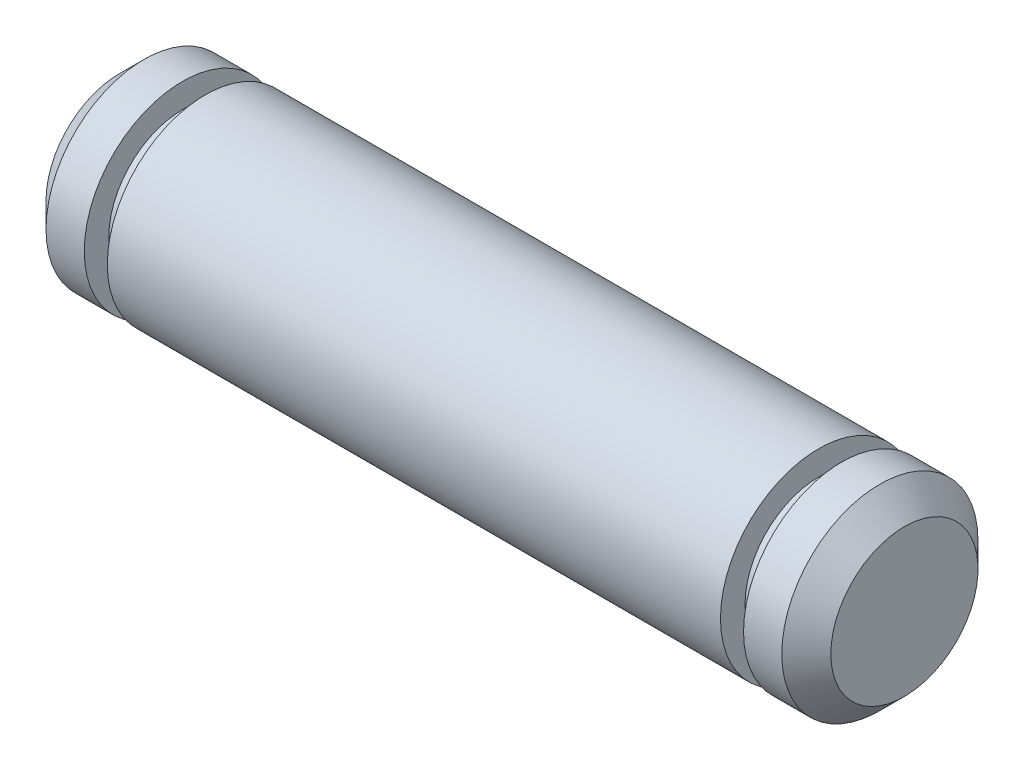
from build123d import *

# Parameters (mm, degrees)
SKETCH1_W = 32
SKETCH1_H = 4
SKETCH4_W = 0.94
SKETCH4_H = 1
SKETCH5_W = 0.94
SKETCH5_H = 1


with BuildPart() as part:
    # Sketch1 → Revolve1 (revolve)
    with BuildSketch(Plane.XY):
        with Locations((0, 2)):
            Rectangle(SKETCH1_W, SKETCH1_H)
    revolve(axis=Axis((16, 0, 0), (-1, 0, 0)))

    # Sketch2 → Cut-Revolve1 (revolve, cut)
    with BuildSketch(Plane.XY):
        Polygon((15, 4), (16, 3), (16, 4), align=None)
    revolve(axis=Axis((16, 0, 0), (-1, 0, 0)), mode=Mode.SUBTRACT)

    # Sketch3 → Cut-Revolve2 (revolve, cut)
    with BuildSketch(Plane.XY):
        Polygon((-16, 3), (-15, 4), (-16, 4), align=None)
    revolve(axis=Axis((16, 0, 0), (-1, 0, 0)), mode=Mode.SUBTRACT)

    # Sketch4 → Cut-Revolve3 (revolve, cut)
    with BuildSketch(Plane.XY):
        with Locations((12.97, 3.5)):
            Rectangle(SKETCH4_W, SKETCH4_H)
    revolve(axis=Axis((16, 0, 0), (-1, 0, 0)), mode=Mode.SUBTRACT)

    # Sketch5 → Cut-Revolve4 (revolve, cut)
    with BuildSketch(Plane.XY):
        with Locations((-12.97, 3.5)):
            Rectangle(SKETCH5_W, SKETCH5_H)
    revolve(axis=Axis((16, 0, 0), (-1, 0, 0)), mode=Mode.SUBTRACT)


solid = part.part
